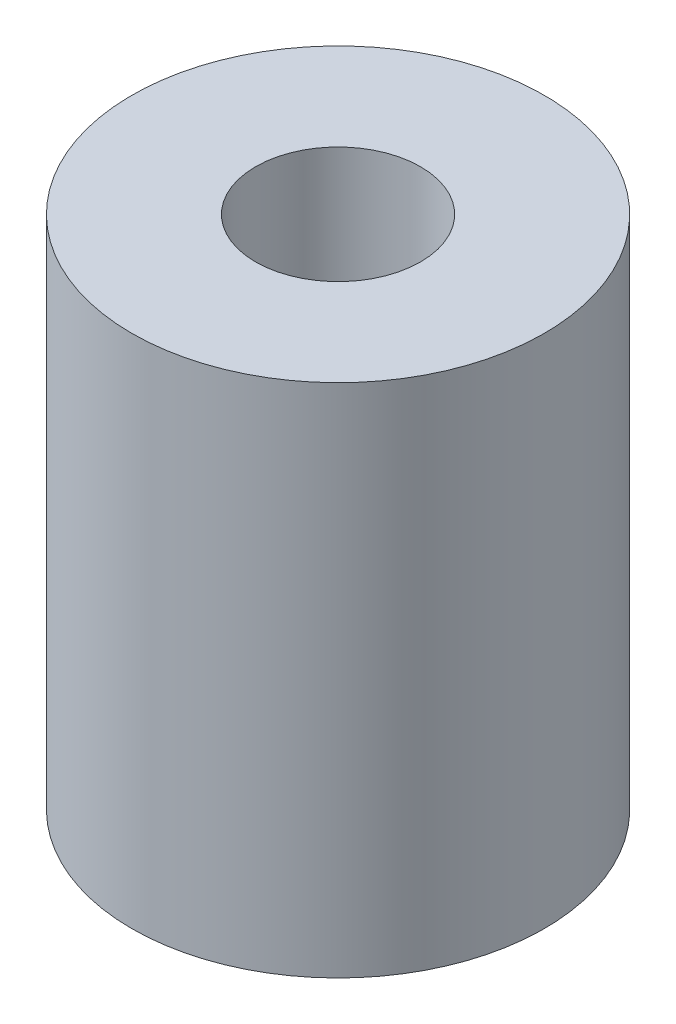
from build123d import *

# Parameters (mm, degrees)
SKETCH1_R           = 4
SKETCH1_R_2         = 1.6
BOSS_EXTRUDE1_DEPTH = 10


with BuildPart() as part:
    # Sketch1 → Boss-Extrude1 (new body)
    with BuildSketch(Plane(origin=(0, 0, 0), x_dir=(1, 0, 0), z_dir=(0, 1, 0))):
        with Locations(Location((0, 0, 0), (0, 0, 270))):  # turned: the seam where the file's is
            Circle(SKETCH1_R)
        with Locations(Location((0, 0, 0), (0, 0, 270))):  # turned: the seam where the file's is
            Circle(SKETCH1_R_2, mode=Mode.SUBTRACT)
    extrude(amount=BOSS_EXTRUDE1_DEPTH)


solid = part.part
